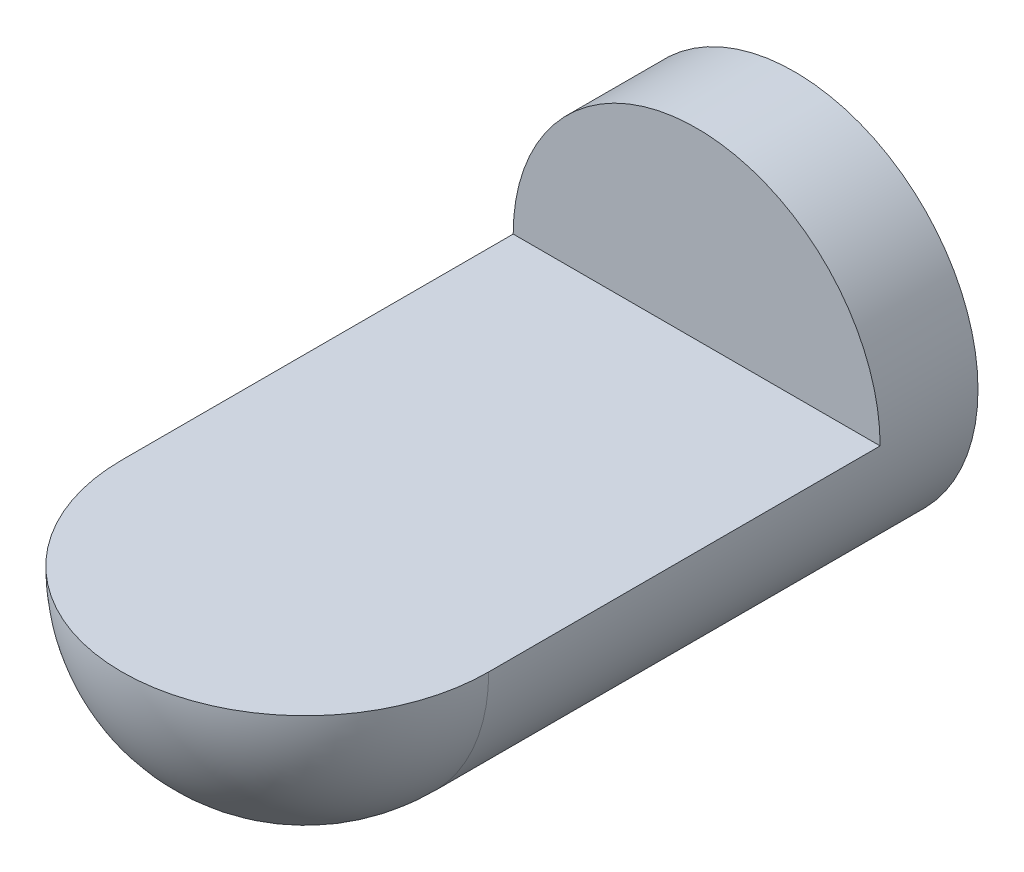
from build123d import *

# Parameters (mm, degrees)
CUT_EXTRUDE1_DEPTH      = 227.384628453
CUT_EXTRUDE1_DEPTH_BACK = 227.384628453


with BuildPart() as part:
    # Sketch1 → Revolve1 (revolve)
    with BuildSketch(Plane(origin=(0, 0, 0), x_dir=(0, 0, -1), z_dir=(1, 0, 0))):
        with BuildLine():
            Line((200, 0), (-75, 0))
            ThreePointArc((-75, 0), (-53.033008589, 53.033008589), (0, 75))
            Line((0, 75), (200, 75))
            Line((200, 75), (200, 0))
        make_face()
    revolve(axis=Axis((0, 0, 146.909145291), (0, 0, -1)))

    # Sketch2 → Cut-Extrude1 (cut, two sides: drawn at the far end of the back side and taken through both)
    with BuildSketch(Plane(origin=(0, 0, 0), x_dir=(0, 0, -1), z_dir=(1, 0, 0)).offset(-CUT_EXTRUDE1_DEPTH_BACK)):
        with BuildLine():
            Line((160, 0), (160, 75))
            Line((160, 75), (0, 75))
            ThreePointArc((0, 75), (-53.033008589, 53.033008589), (-75, 0))
            Line((-75, 0), (160, 0))
        make_face()
    extrude(amount=CUT_EXTRUDE1_DEPTH + CUT_EXTRUDE1_DEPTH_BACK, mode=Mode.SUBTRACT)


solid = part.part
